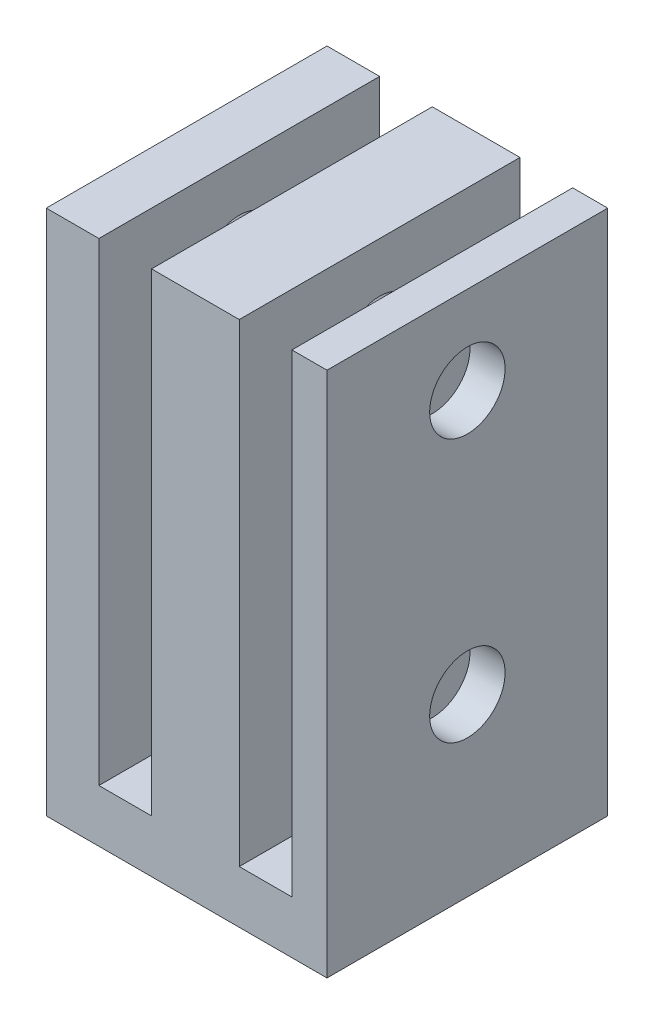
from build123d import *

# Parameters (mm, degrees)
SKETCH1_W           = 16
SKETCH1_H           = 16
BOSS_EXTRUDE1_DEPTH = 30
SKETCH2_W           = 3
SKETCH2_H           = 27
CUT_EXTRUDE1_DEPTH  = 17
SKETCH3_R           = 2.15
CUT_EXTRUDE2_DEPTH  = 17


with BuildPart() as part:
    # Sketch1 → Boss-Extrude1 (new body)
    with BuildSketch(Plane(origin=(0, 0, 0), x_dir=(1, 0, 0), z_dir=(0, 1, 0))):
        with Locations((8, 8)):
            Rectangle(SKETCH1_W, SKETCH1_H)
    extrude(amount=BOSS_EXTRUDE1_DEPTH)

    # Sketch2 → Cut-Extrude1 (cut, through all)
    with BuildSketch(Plane.XY):
        with Locations((4.5, 16.5)):
            Rectangle(SKETCH2_W, SKETCH2_H)
        with Locations((12.5, 16.5)):
            Rectangle(SKETCH2_W, SKETCH2_H)
    extrude(amount=-CUT_EXTRUDE1_DEPTH, mode=Mode.SUBTRACT)

    # Sketch3 → Cut-Extrude2 (cut, through all)
    with BuildSketch(Plane.ZY):
        with Locations((-8, 25)):
            Circle(SKETCH3_R)
        with Locations((-8, 10)):
            Circle(SKETCH3_R)
    extrude(amount=-CUT_EXTRUDE2_DEPTH, mode=Mode.SUBTRACT)


solid = part.part
